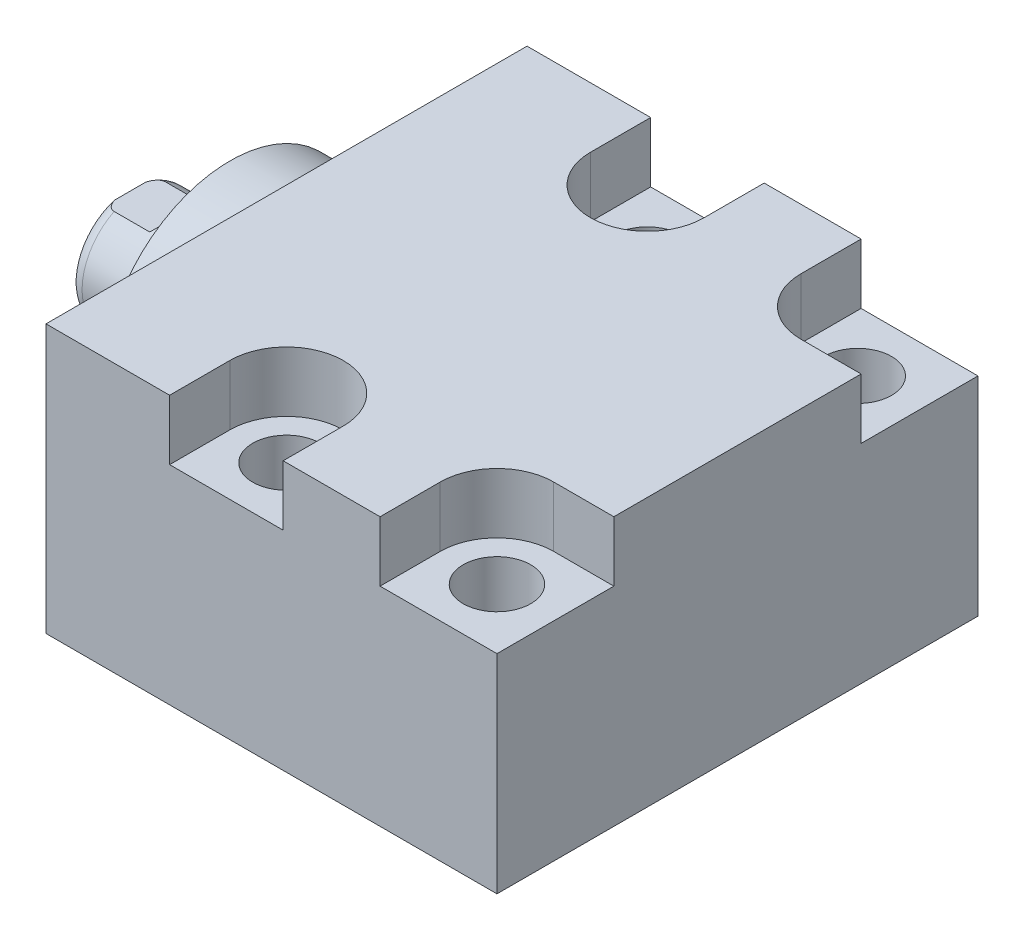
from build123d import *

# Parameters (mm, degrees)
SKETCH1_W          = 50.8
SKETCH1_H          = 28.321
EXTRUDE1_DEPTH     = 47.625
SKETCH5_R          = 13.5001
EXTRUDE2_DEPTH     = 5.969
SKETCH6_W          = 6.35
SKETCH6_H          = 10.541
CUT_EXTRUDE4_DEPTH = 30.48
HOLE2_D            = 7.1374
HOLE2_DEPTH        = 28.321
LPATTERN1_COUNT    = 2
LPATTERN1_PITCH    = 22.225
CUT_EXTRUDE5_DEPTH = 6.35
HOLE3_D            = 2.3876
HOLE3_DEPTH        = 14.224
HOLE3_CBORE_D      = 11.3411
HOLE3_CBORE_DEPTH  = 1.4478
HOLE3_TIP          = 0.717307407
HOLE4_D            = 3.175
HOLE4_DEPTH        = 14.224
HOLE4_TIP          = 0.953866233
SKETCH26_R         = 5.6769
CUT_EXTRUDE6_DEPTH = 1.4478
CHAMFER1_SIZE      = 0.635
SKETCH23_R         = 1.4478
LPATTERN3_COUNT    = 2
LPATTERN3_PITCH    = 22.225


with BuildPart() as part:
    # Sketch1 → Extrude1 (new body)
    with BuildSketch(Plane(origin=(0, 0, 0), x_dir=(0, 0, -1), z_dir=(1, 0, 0))):
        with Locations((0, 0.1143)):
            Rectangle(SKETCH1_W, SKETCH1_H)
    extrude(amount=EXTRUDE1_DEPTH)

    # Sketch5 → Extrude2 (add)
    with BuildSketch(Plane.ZY):
        Circle(SKETCH5_R)
    extrude(amount=EXTRUDE2_DEPTH)

    # Sketch6 → Revolve1 (revolve)
    with BuildSketch(Plane(origin=(0, 0, 0), x_dir=(0, 0, 1), z_dir=(0, -1, 0)), mode=Mode.PRIVATE) as revolve1_sk:
        with Locations((-3.175, 11.2395)):
            Rectangle(SKETCH6_W, SKETCH6_H)
    revolve(revolve1_sk.sketch.rotate(Axis((5.754582971, 0, 0), (-1, 0, 0)), 180), axis=Axis((5.754582971, 0, 0), (-1, 0, 0)))  # turned: the seam where the file's is

    # S2D0001 → Cut-Revolve4 (revolve, cut)
    with BuildSketch(Plane(origin=(-18.511260017, 3.2639, 0), x_dir=(0, 1, 0), z_dir=(0, 0, 1)), mode=Mode.PRIVATE) as cut_revolve4_sk:
        Polygon((-0.7112, -3.563050231), (-0.7112, -18.003260017), (-3.2639, -19.53707692), (-3.2639, -2.001260017), (0.1905, -2.001260017), align=None)
    revolve(cut_revolve4_sk.sketch.rotate(Axis((0, 0, 0), (-1, 0, 0)), 90), axis=Axis((0, 0, 0), (-1, 0, 0)), mode=Mode.SUBTRACT)  # turned: the seam where the file's is

    # Sketch8 → Cut-Revolve5 (revolve, cut)
    with BuildSketch(Plane(origin=(0, 0, 0), x_dir=(0, 0, -1), z_dir=(0, 1, 0)), mode=Mode.PRIVATE) as cut_revolve5_sk:
        with BuildLine():
            Line((-6.35, 10.1854), (-6.096, 10.9474))
            Line((-6.096, 10.9474), (-6.096, 15.494))
            ThreePointArc((-6.096, 15.494), (-5.995678675, 16.037796865), (-5.707922533, 16.51))
            Line((-5.707922533, 16.51), (-6.35, 16.51))
            Line((-6.35, 16.51), (-6.35, 10.1854))
        make_face()
    revolve(cut_revolve5_sk.sketch.rotate(Axis((-12.65936, 0, 0), (-1, 0, 0)), 180), axis=Axis((-12.65936, 0, 0), (-1, 0, 0)), mode=Mode.SUBTRACT)  # turned: the seam where the file's is

    # Sketch12 → Cut-Extrude4 (cut, symmetric)
    with BuildSketch(Plane(origin=(0, 0, 0), x_dir=(0, -1, 0), z_dir=(0, 0, -1))):
        Polygon((5.461, 16.51), (5.461, 11.7348), (6.096, 11.0998), (6.096, 16.51), align=None)
        Polygon((-5.461, 16.51), (-5.461, 11.7348), (-6.096, 11.0998), (-6.096, 16.51), align=None)
    extrude(amount=CUT_EXTRUDE4_DEPTH, both=True, mode=Mode.SUBTRACT)

    # Hole2
    with Locations(Plane(origin=(0, 14.2748, 0), x_dir=(-1, 0, 0), z_dir=(0, 1, 0))):
        with Locations((-19.05, -19.05), (-19.05, 19.05)):
            hole2 = Hole(HOLE2_D / 2, depth=HOLE2_DEPTH)

    # LPattern1: Hole2 ×2
    with Locations(*[(i * LPATTERN1_PITCH, 0, 0) for i in range(1, LPATTERN1_COUNT)]):
        add(hole2, mode=Mode.SUBTRACT)

    # Sketch18 → Cut-Extrude5 (cut)
    with BuildSketch(Plane(origin=(0, 14.2748, 0), x_dir=(1, 0, 0), z_dir=(0, 1, 0))):
        with BuildLine():
            Line((47.625, -25.4), (35.2806, -25.4))
            Line((35.2806, -25.4), (35.2806, -19.05))
            ThreePointArc((35.2806, -19.05), (37.036319111, -14.811319111), (41.275, -13.0556))
            Line((41.275, -13.0556), (47.625, -13.0556))
            Line((47.625, -13.0556), (47.625, -25.4))
        make_face()
        with BuildLine():
            Line((13.0556, -19.05), (13.0556, -25.4))
            Line((13.0556, -25.4), (25.0444, -25.4))
            Line((25.0444, -25.4), (25.0444, -19.05))
            ThreePointArc((25.0444, -19.05), (19.05, -13.0556), (13.0556, -19.05))
        make_face()
        with BuildLine():
            Line((47.625, 13.0556), (47.625, 25.4))
            Line((47.625, 25.4), (35.2806, 25.4))
            Line((35.2806, 25.4), (35.2806, 19.05))
            ThreePointArc((35.2806, 19.05), (37.036319111, 14.811319111), (41.275, 13.0556))
            Line((41.275, 13.0556), (47.625, 13.0556))
        make_face()
        with BuildLine():
            Line((25.0444, 25.4), (13.0556, 25.4))
            Line((13.0556, 25.4), (13.0556, 19.05))
            ThreePointArc((13.0556, 19.05), (19.05, 13.0556), (25.0444, 19.05))
            Line((25.0444, 19.05), (25.0444, 25.4))
        make_face()
    extrude(amount=-CUT_EXTRUDE5_DEPTH, mode=Mode.SUBTRACT)

    # Hole3
    with Locations(Plane.XZ.offset(14.0462)):
        with Locations((12.7, 0)):
            CounterBoreHole(HOLE3_D / 2, HOLE3_CBORE_D / 2, HOLE3_CBORE_DEPTH, depth=HOLE3_DEPTH)
            with Locations((0, 0, -(HOLE3_DEPTH + HOLE3_TIP / 2))):  # 118° drill point
                Cone(0, HOLE3_D / 2, HOLE3_TIP, mode=Mode.SUBTRACT)

    # Hole4
    with Locations(Plane.XZ.offset(14.0462)):
        with Locations((36.3474, 0)):
            Hole(HOLE4_D / 2, depth=HOLE4_DEPTH)
            with Locations((0, 0, -(HOLE4_DEPTH + HOLE4_TIP / 2))):  # 118° drill point
                Cone(0, HOLE4_D / 2, HOLE4_TIP, mode=Mode.SUBTRACT)

    # Sketch26 → Cut-Extrude6 (cut)
    with BuildSketch(Plane.XZ.offset(14.0462)):
        with Locations(Location((34.925, 0, 0), (0, 0, 270))):  # turned: the seam where the file's is
            Circle(SKETCH26_R)
    extrude(amount=-CUT_EXTRUDE6_DEPTH, mode=Mode.SUBTRACT)

    # Chamfer1
    chamfer1_edges = [part.edges().sort_by_distance(p)[0] for p in [
        (13.8938, -12.5984, 0),
        (37.9349, -12.5984, 0),
    ]]
    chamfer(chamfer1_edges, length=CHAMFER1_SIZE)


with BuildPart() as body_2:
    # Sketch23 → Revolve2 (revolve)
    with BuildSketch(Plane.XY, mode=Mode.PRIVATE) as revolve2_sk:
        with Locations((8.47725, -14.0462)):
            Circle(SKETCH23_R)
    revolve(revolve2_sk.sketch.rotate(Axis((12.7, -12.5984, 0), (0, -1, 0)), 90), axis=Axis((12.7, -12.5984, 0), (0, -1, 0)))  # turned: the seam where the file's is


with BuildPart() as lpattern3_1:
    # LPattern3: pattern copy
    add(body_2.part.moved(Location(Vector(1, 0, 0) * (1 * LPATTERN3_PITCH))))


solid = Compound([part.part, body_2.part, lpattern3_1.part])
